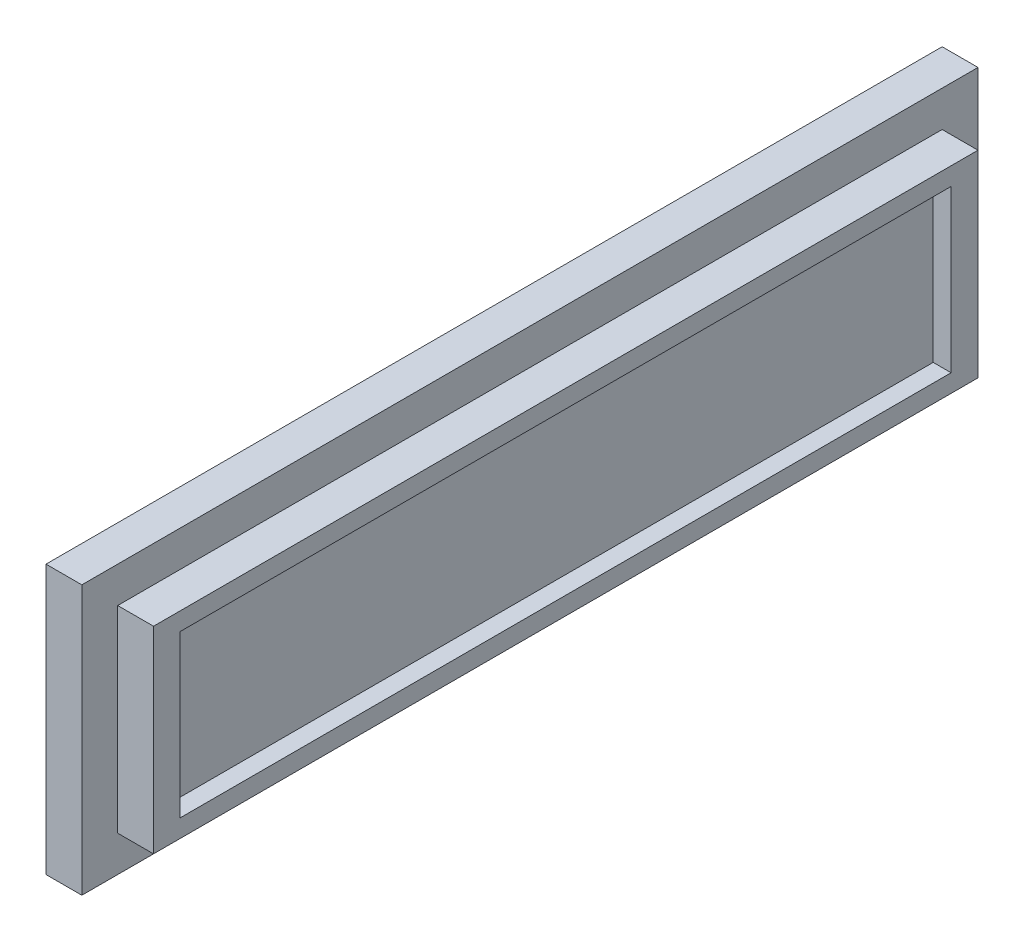
from build123d import *

# Parameters (mm, degrees)
SKETCH2_W           = 50
SKETCH2_H           = 15
BOSS_EXTRUDE1_DEPTH = 2
SKETCH4_W           = 46
SKETCH4_H           = 11
BOSS_EXTRUDE2_DEPTH = 2
SKETCH5_W           = 43.009657984
SKETCH5_H           = 9.00272897
CUT_EXTRUDE1_DEPTH  = 1


with BuildPart() as part:
    # Sketch2 → Boss-Extrude1 (new body)
    with BuildSketch(Plane(origin=(0, 0, 0), x_dir=(0, 0, -1), z_dir=(1, 0, 0))):
        with Locations((-3.923357664, -3.48540146)):
            Rectangle(SKETCH2_W, SKETCH2_H)
    extrude(amount=BOSS_EXTRUDE1_DEPTH)

    # Sketch4 → Boss-Extrude2 (add)
    with BuildSketch(Plane(origin=(2, 0, 0), x_dir=(0, 0, -1), z_dir=(1, 0, 0))):
        with Locations((-3.923357664, -3.48540146)):
            Rectangle(SKETCH4_W, SKETCH4_H)
    extrude(amount=BOSS_EXTRUDE2_DEPTH)

    # Sketch5 → Cut-Extrude1 (cut)
    with BuildSketch(Plane(origin=(4, 0, 0), x_dir=(0, 0, -1), z_dir=(1, 0, 0))):
        with Locations((-3.928186656, -3.486765945)):
            Rectangle(SKETCH5_W, SKETCH5_H)
    extrude(amount=-CUT_EXTRUDE1_DEPTH, mode=Mode.SUBTRACT)


solid = part.part
